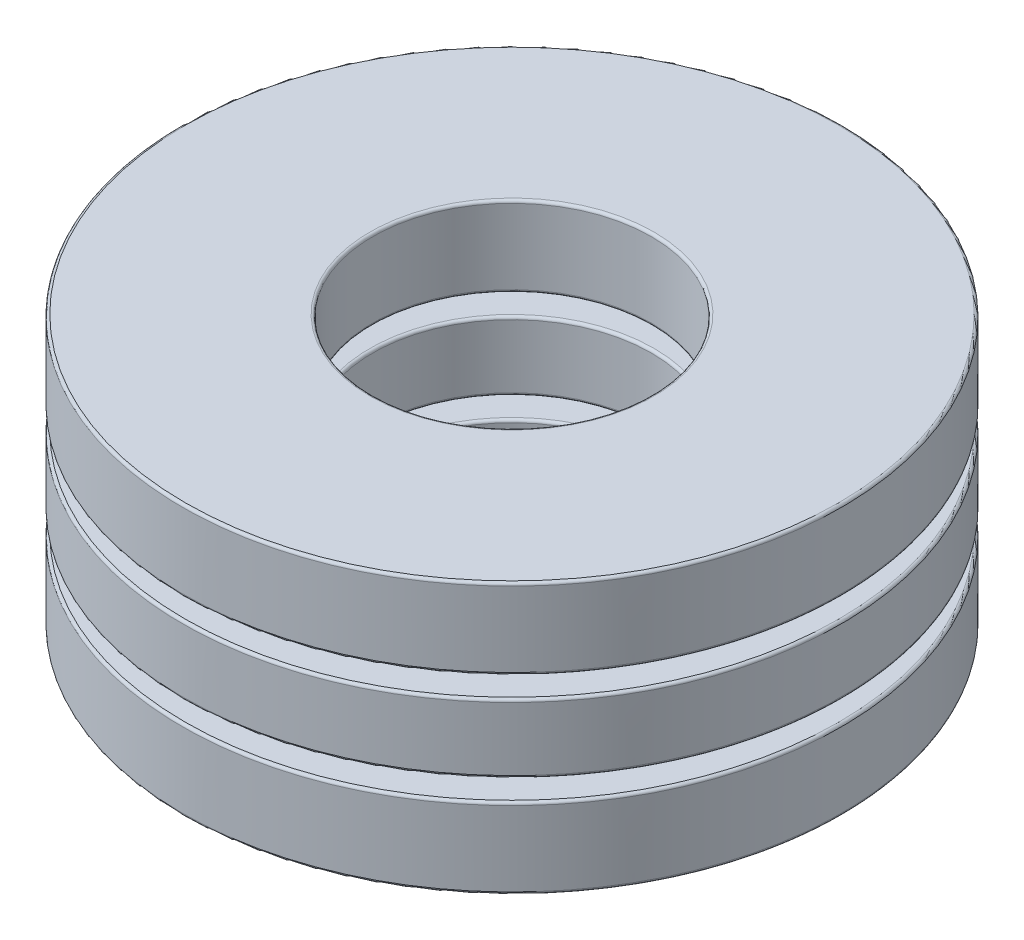
from build123d import *

# Parameters (mm, degrees)
SKETCH1_W         = 3.462
SKETCH1_H         = 1.25
CIRPATTERN1_COUNT = 7
CIRPATTERN1_ANGLE = 308.571428571
CIRPATTERN2_COUNT = 7
SKETCH4_W         = 3.462
SKETCH4_H         = 1.46
FILLET1_R         = 0.0492
FILLET2_R         = 0.0492
FILLET3_R         = 0.0492


with BuildPart() as part:
    # Sketch1 → Revolve1 (revolve)
    with BuildSketch(Plane(origin=(0, 0, 0), x_dir=(0, 0, -1), z_dir=(1, 0, 0))):
        with Locations((-4.269, 0)):
            Rectangle(SKETCH1_W, SKETCH1_H)
    revolve(axis=Axis((0, -2.46, 0), (0, 1, 0)))

    # Sketch3 → Cut-Revolve1 (revolve, cut)
    with BuildSketch(Plane(origin=(0, 0, 0), x_dir=(0, 0, -1), z_dir=(1, 0, 0))):
        with BuildLine():
            Line((-4.5, 1.0625), (-4.5, -1.0625))
            ThreePointArc((-4.5, -1.0625), (-5.5625, 0), (-4.5, 1.0625))
        make_face()
    cut_revolve1 = revolve(axis=Axis((0, 1.0625, 4.5), (0, -1, 0)), mode=Mode.SUBTRACT)

    # CirPattern2: Cut-Revolve1 ×7 about axis
    cirpattern2_axis = Axis((0, 0, 0), (0, 1, 0))
    for i in range(1, CIRPATTERN2_COUNT):
        add(cut_revolve1.rotate(cirpattern2_axis, i * 360 / CIRPATTERN2_COUNT), mode=Mode.SUBTRACT)

    # Fillet2
    fillet2_edges = [part.edges().sort_by_distance(p)[0] for p in [
        (0, 0.625, -6),
        (0, 0.625, -2.538),
        (0, -0.625, -2.538),
        (0, -0.625, -6),
    ]]
    fillet(fillet2_edges, radius=FILLET2_R)


with BuildPart() as body_2:
    # Sketch2 → Revolve2 (revolve)
    with BuildSketch(Plane(origin=(0, 0, 0), x_dir=(0, 0, -1), z_dir=(1, 0, 0))):
        with BuildLine():
            Line((-4.5, 1), (-4.5, -1))
            ThreePointArc((-4.5, -1), (-5.5, 0), (-4.5, 1))
        make_face()
    revolve(axis=Axis((0, 1, 4.5), (0, -1, 0)))


with BuildPart() as cirpattern1_1:
    # CirPattern1: pattern copy
    add(body_2.part.rotate(Axis((0, 2.46, 0), (0, -1, 0)), 1 * CIRPATTERN1_ANGLE / (CIRPATTERN1_COUNT - 1)))


with BuildPart() as cirpattern1_2:
    # CirPattern1: pattern copy
    add(body_2.part.rotate(Axis((0, 2.46, 0), (0, -1, 0)), 2 * CIRPATTERN1_ANGLE / (CIRPATTERN1_COUNT - 1)))


with BuildPart() as cirpattern1_3:
    # CirPattern1: pattern copy
    add(body_2.part.rotate(Axis((0, 2.46, 0), (0, -1, 0)), 3 * CIRPATTERN1_ANGLE / (CIRPATTERN1_COUNT - 1)))


with BuildPart() as cirpattern1_4:
    # CirPattern1: pattern copy
    add(body_2.part.rotate(Axis((0, 2.46, 0), (0, -1, 0)), 4 * CIRPATTERN1_ANGLE / (CIRPATTERN1_COUNT - 1)))


with BuildPart() as cirpattern1_5:
    # CirPattern1: pattern copy
    add(body_2.part.rotate(Axis((0, 2.46, 0), (0, -1, 0)), 5 * CIRPATTERN1_ANGLE / (CIRPATTERN1_COUNT - 1)))


with BuildPart() as cirpattern1_6:
    # CirPattern1: pattern copy
    add(body_2.part.rotate(Axis((0, 2.46, 0), (0, -1, 0)), 6 * CIRPATTERN1_ANGLE / (CIRPATTERN1_COUNT - 1)))


with BuildPart() as body_9:
    # Sketch4 → Revolve3 (revolve)
    with BuildSketch(Plane(origin=(0, 0, 0), x_dir=(0, 0, -1), z_dir=(1, 0, 0))):
        with Locations((-4.269, 1.73)):
            Rectangle(SKETCH4_W, SKETCH4_H)
        with Locations((-4.269, -1.73)):
            Rectangle(SKETCH4_W, SKETCH4_H)
    revolve(axis=Axis((0, -2.46, 0), (0, 1, 0)))

    # Fillet1
    fillet1_edges = [body_9.edges().sort_by_distance(p)[0] for p in [
        (0, 1, -6),
        (0, 1, -2.538),
        (0, 2.46, -2.538),
        (0, 2.46, -6),
    ]]
    fillet(fillet1_edges, radius=FILLET1_R)

    # Fillet3
    fillet3_edges = [body_9.edges().sort_by_distance(p)[0] for p in [
        (0, -2.46, -6),
        (0, -2.46, -2.538),
        (0, -1, -2.538),
        (0, -1, -6),
    ]]
    fillet(fillet3_edges, radius=FILLET3_R)


solid = Compound([part.part, body_2.part, cirpattern1_1.part, cirpattern1_2.part, cirpattern1_3.part, cirpattern1_4.part, cirpattern1_5.part, cirpattern1_6.part, body_9.part])
